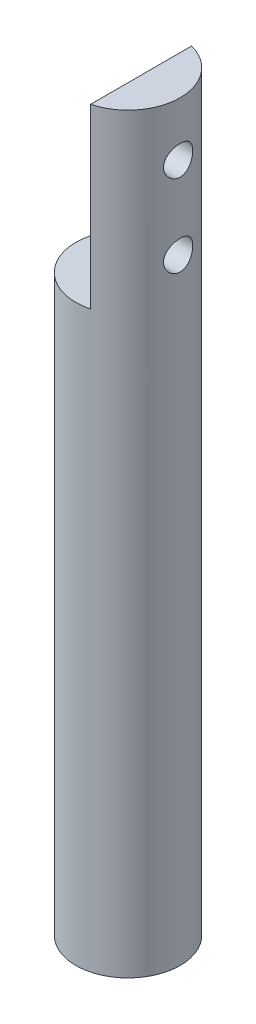
from build123d import *

# Parameters (mm, degrees)
SKETCH_1_R          = 3.175
EXTRUDE_1_DEPTH     = 57.15
CUT_EXTRUDE_1_DEPTH = 10.795
SKETCH_3_R          = 0.889
CUT_EXTRUDE_2_DEPTH = 10.795
SKETCH_4_W          = 3.926157487
SKETCH_4_H          = 0.79375
CUT_EXTRUDE_3_DEPTH = 8.573
SKETCH_5_R          = 3.774888962
CUT_EXTRUDE_4_DEPTH = 11.4


with BuildPart() as part:
    # 草图1 → 凸台-拉伸1 (new body)
    with BuildSketch(Plane(origin=(0, 0, 0), x_dir=(1, 0, 0), z_dir=(0, 1, 0))):
        Circle(SKETCH_1_R)
    extrude(amount=EXTRUDE_1_DEPTH)

    # 草图2 → 切除-拉伸1 (cut)
    with BuildSketch(Plane(origin=(0, 57.15, 0), x_dir=(1, 0, 0), z_dir=(0, 1, 0))):
        Polygon((-0.794, 3.175), (0.794, 3.175), (0.794, -3.175), (-3.175, -3.175), (-3.175, 3.175), align=None)
    extrude(amount=-CUT_EXTRUDE_1_DEPTH, mode=Mode.SUBTRACT)

    # 草图3 → 切除-拉伸2 (cut)
    with BuildSketch(Plane.ZY.offset(-0.794)):
        with Locations((0, 53.855)):
            Circle(SKETCH_3_R)
        with Locations((0, 48.855)):
            Circle(SKETCH_3_R)
    extrude(amount=-CUT_EXTRUDE_2_DEPTH, mode=Mode.SUBTRACT)

    # 草图4 → 切除-拉伸3 (cut)
    with BuildSketch(Plane.XZ):
        with Locations((-0.018009896, -2.778125)):
            Rectangle(SKETCH_4_W, SKETCH_4_H)
    extrude(amount=-CUT_EXTRUDE_3_DEPTH, mode=Mode.SUBTRACT)

    # 草图5 → 切除-拉伸4 (cut)
    with BuildSketch(Plane.XZ):
        Circle(SKETCH_5_R)
    extrude(amount=-CUT_EXTRUDE_4_DEPTH, mode=Mode.SUBTRACT)


solid = part.part
